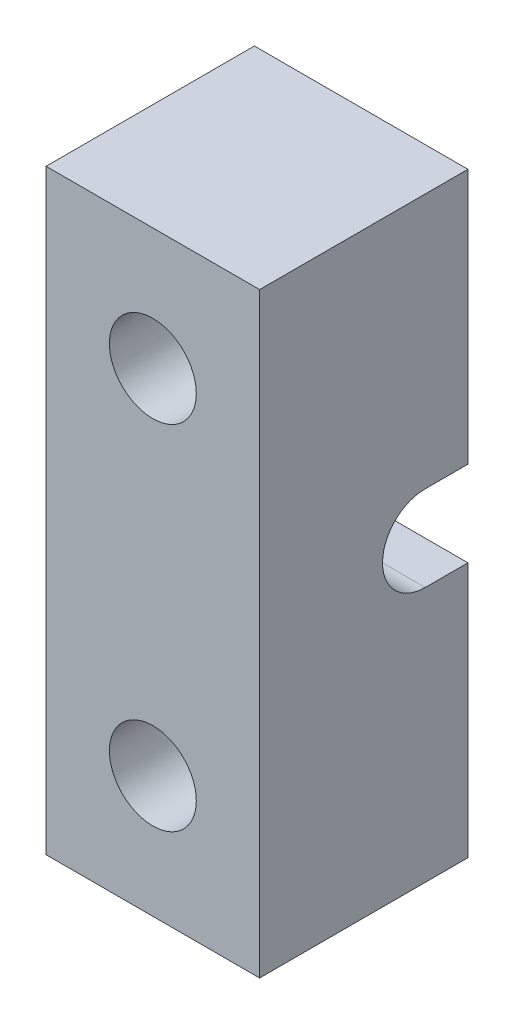
from build123d import *

# Parameters (mm, degrees)
SKETCH1_W               = 15.377554838
SKETCH1_H               = 42.931213808
SKETCH1_R               = 3.129225598
BOSS_EXTRUDE1_DEPTH     = 15
CUT_EXTRUDE1_DEPTH      = 1
CUT_EXTRUDE1_DEPTH_BACK = 16.377554838


with BuildPart() as part:
    # Sketch1 → Boss-Extrude1 (new body)
    with BuildSketch(Plane.XY):
        with Locations((215.9, 0)):
            Rectangle(SKETCH1_W, SKETCH1_H)
        with Locations((215.9, -12.7)):
            Circle(SKETCH1_R, mode=Mode.SUBTRACT)
        with Locations((215.9, 12.7)):
            Circle(SKETCH1_R, mode=Mode.SUBTRACT)
    extrude(amount=BOSS_EXTRUDE1_DEPTH)

    # Sketch2 → Cut-Extrude1 (cut, two sides)
    with BuildSketch(Plane(origin=(223.588777419, 0, 0), x_dir=(0, 0, -1), z_dir=(1, 0, 0))) as cut_extrude1_sk:
        with BuildLine():
            Line((0, -3.075), (-3.075, -3.075))
            ThreePointArc((-3.075, -3.075), (-6.15, 0), (-3.075, 3.075))
            Line((-3.075, 3.075), (0, 3.075))
            ThreePointArc((0, 3.075), (3.075, 0), (0, -3.075))
        make_face()
    extrude(amount=CUT_EXTRUDE1_DEPTH, mode=Mode.SUBTRACT)
    extrude(cut_extrude1_sk.sketch, amount=-CUT_EXTRUDE1_DEPTH_BACK, mode=Mode.SUBTRACT)


solid = part.part
